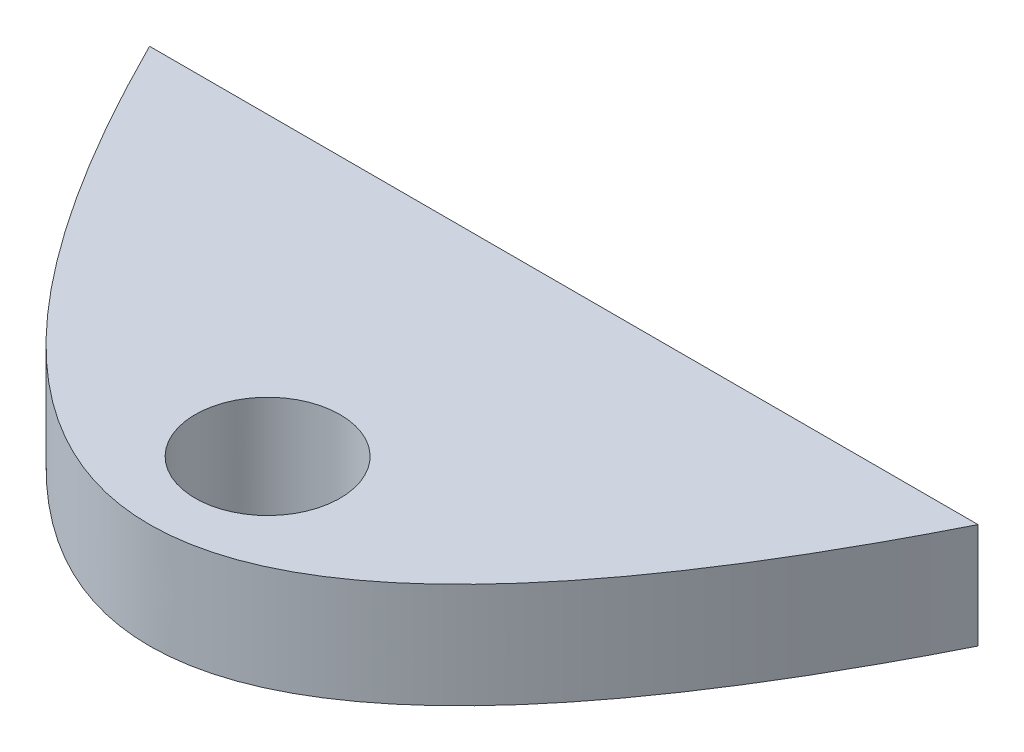
from build123d import *

# Parameters (mm, degrees)
BOSS_EXTRUDE1_DEPTH     = 300
SKETCH3_R               = 15.5
CUT_EXTRUDE1_DEPTH      = 23
CUT_EXTRUDE1_DEPTH_BACK = 23
SKETCH4_R               = 35
CUT_EXTRUDE3_DEPTH      = 300
SKETCH5_W               = 523.788834898
SKETCH5_H               = 264.11010626
CUT_EXTRUDE4_DEPTH      = 300


with BuildPart() as part:
    # Sketch1 → Boss-Extrude1 (new body)
    with BuildSketch(Plane(origin=(0, 0, 0), x_dir=(1, 0, 0), z_dir=(0, 1, 0))):
        with BuildLine():
            Line((-200, 1e-09), (200, 1e-09))
            add(Edge.make_bspline(
                [(-200, 1e-09), (0, -400.000000001), (200, 1e-09)],
                knots=[0.056028396, 0.056028396, 0.056028396, 0.943971604, 0.943971604, 0.943971604], degree=2))
        make_face()
    extrude(amount=BOSS_EXTRUDE1_DEPTH)

    # Sketch3 → Cut-Extrude1 (cut, two sides)
    with BuildSketch(Plane(origin=(0, 150, 0), x_dir=(1, 0, 0), z_dir=(0, 1, 0))) as cut_extrude1_sk:
        with Locations((0, -142.999999999)):
            Circle(SKETCH3_R)
    extrude(amount=CUT_EXTRUDE1_DEPTH, mode=Mode.SUBTRACT)
    extrude(cut_extrude1_sk.sketch, amount=-CUT_EXTRUDE1_DEPTH_BACK, mode=Mode.SUBTRACT)

    # Sketch4 → Cut-Extrude3 (cut)
    with BuildSketch(Plane(origin=(0, 173, 0), x_dir=(1, 0, 0), z_dir=(0, 1, 0))):
        with Locations((0, -142.999999999)):
            Circle(SKETCH4_R)
    cut_extrude3 = extrude(amount=CUT_EXTRUDE3_DEPTH, mode=Mode.SUBTRACT)

    # Mirror1: Cut-Extrude3 across plane
    add(cut_extrude3.mirror(Plane.ZX.offset(150)), mode=Mode.SUBTRACT)

    # Sketch5 → Cut-Extrude4 (cut)
    with BuildSketch(Plane(origin=(0, 0, 0), x_dir=(-1, 0, 0), z_dir=(0, 0, -1))):
        with Locations((5.096084265, 117.14494687)):
            Rectangle(SKETCH5_W, SKETCH5_H)
    extrude(amount=-CUT_EXTRUDE4_DEPTH, mode=Mode.SUBTRACT)


solid = part.part
